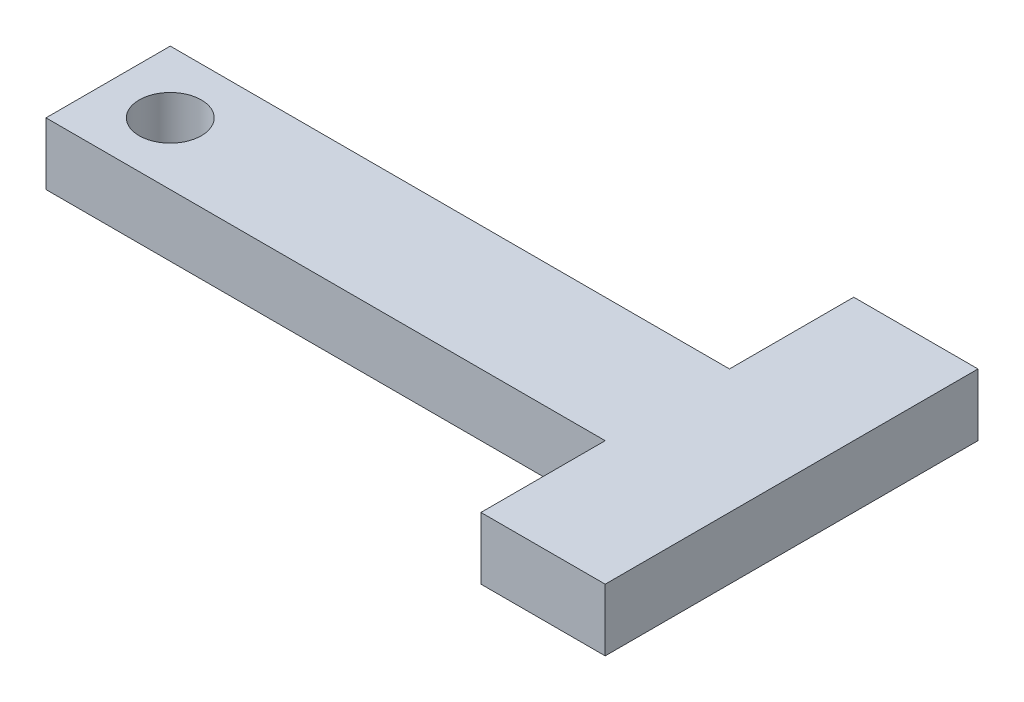
from build123d import *

# Parameters (mm, degrees)
SKETCH1_R           = 5
BOSS_EXTRUDE1_DEPTH = 10


with BuildPart() as part:
    # Sketch1 → Boss-Extrude1 (new body)
    with BuildSketch(Plane(origin=(0, 0, 0), x_dir=(1, 0, 0), z_dir=(0, 1, 0))):
        Polygon((90, 20), (90, 40), (110, 40), (110, -20), (90, -20), (90, 0), (0, 0), (0, 20), align=None)
        with Locations((10, 10)):
            Circle(SKETCH1_R, mode=Mode.SUBTRACT)
    extrude(amount=BOSS_EXTRUDE1_DEPTH)


solid = part.part
